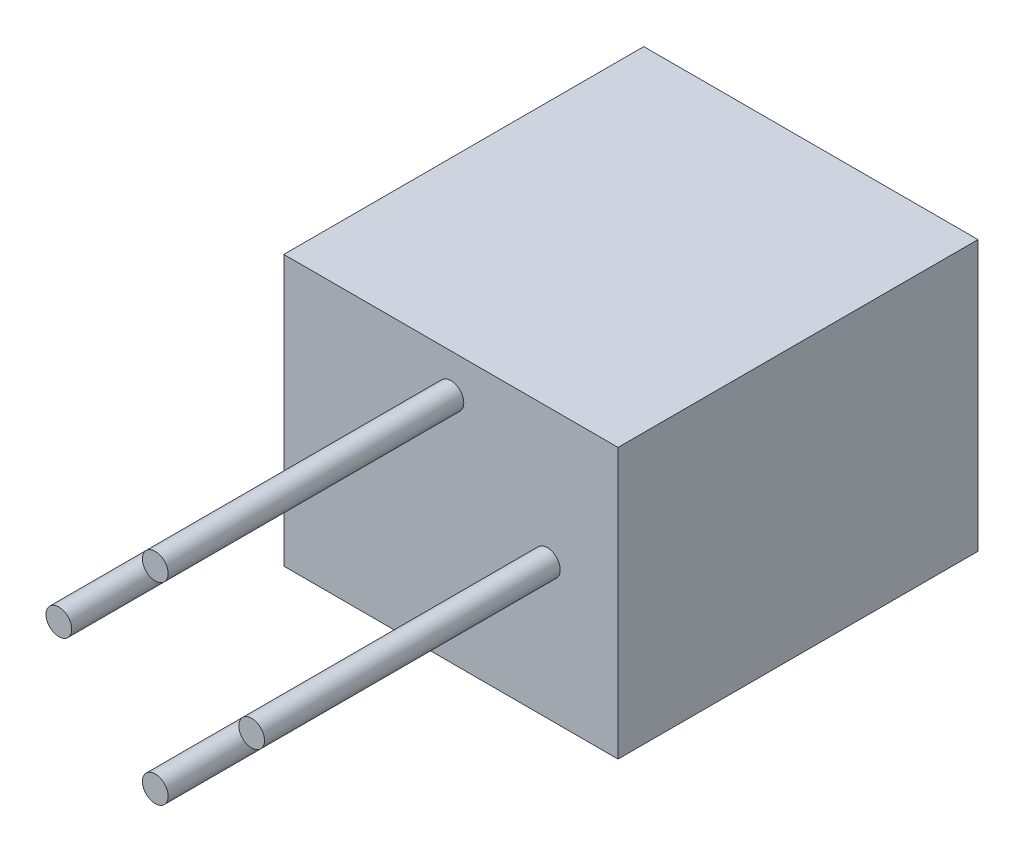
from build123d import *

# Parameters (mm, degrees)
SKETCH1_W           = 26
SKETCH1_H           = 21
SKETCH1_W_2         = 20
SKETCH1_H_2         = 15
BOSS_EXTRUDE1_DEPTH = 25
SKETCH2_W           = 26
SKETCH2_H           = 21
BOSS_EXTRUDE2_DEPTH = 3
SKETCH3_R           = 1
BOSS_EXTRUDE3_DEPTH = 23


with BuildPart() as part:
    # Sketch1 → Boss-Extrude1 (new body)
    with BuildSketch(Plane.XY):
        with Locations((5, 0)):
            Rectangle(SKETCH1_W, SKETCH1_H)
        with Locations((5, 0)):
            Rectangle(SKETCH1_W_2, SKETCH1_H_2, mode=Mode.SUBTRACT)
    extrude(amount=-BOSS_EXTRUDE1_DEPTH)

    # Sketch2 → Boss-Extrude2 (add)
    with BuildSketch(Plane.XY):
        with Locations((5, 0)):
            Rectangle(SKETCH2_W, SKETCH2_H)
    extrude(amount=BOSS_EXTRUDE2_DEPTH)

    # Sketch3 → Boss-Extrude3 (add)
    with BuildSketch(Plane.XY.offset(3)):
        with Locations((12.5, 0)):
            Circle(SKETCH3_R)
        with Locations((5, -7.5)):
            Circle(SKETCH3_R)
        with Locations((-2.5, 0)):
            Circle(SKETCH3_R)
        with Locations((5, 7.5)):
            Circle(SKETCH3_R)
    extrude(amount=BOSS_EXTRUDE3_DEPTH)


solid = part.part
